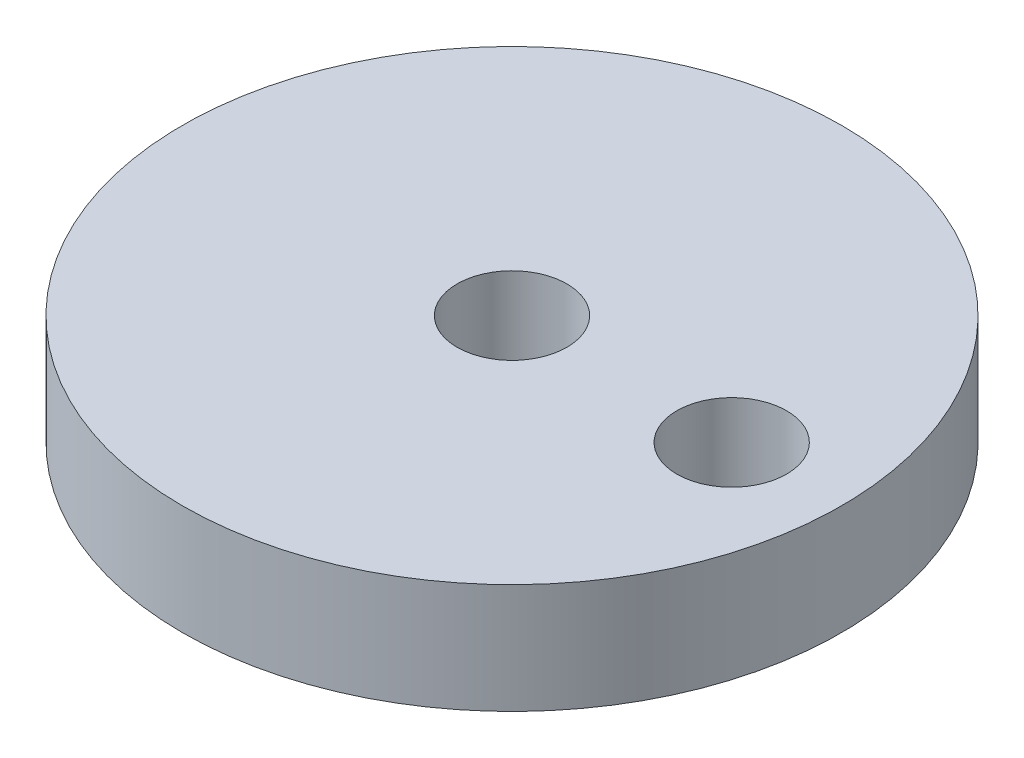
from build123d import *

# Parameters (mm, degrees)
SKETCH1_R           = 30
SKETCH1_R_2         = 5
BOSS_EXTRUDE1_DEPTH = 10


with BuildPart() as part:
    # Sketch1 → Boss-Extrude1 (new body)
    with BuildSketch(Plane(origin=(0, 0, 0), x_dir=(1, 0, 0), z_dir=(0, 1, 0))):
        Circle(SKETCH1_R)
        Circle(SKETCH1_R_2, mode=Mode.SUBTRACT)
        with Locations((20, 0)):
            Circle(SKETCH1_R_2, mode=Mode.SUBTRACT)
    extrude(amount=BOSS_EXTRUDE1_DEPTH)


solid = part.part
